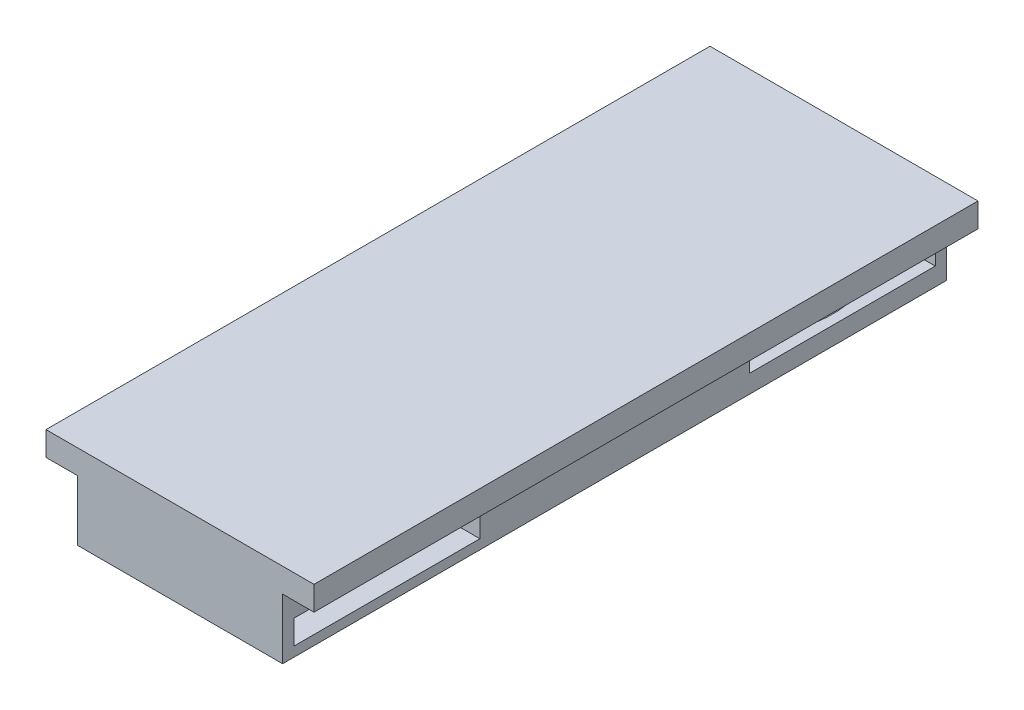
from build123d import *

# Parameters (mm, degrees)
BOSS_EXTRUDE1_DEPTH = 55
SKETCH3_R           = 7.7
CUT_EXTRUDE1_DEPTH  = 2.8
SKETCH4_R           = 7.7
SKETCH4_R_2         = 5.5
BOSS_EXTRUDE2_DEPTH = 0.8
SKETCH5_W           = 15.4
SKETCH5_H           = 2
CUT_EXTRUDE2_DEPTH  = 8.5


with BuildPart() as part:
    # Sketch2 → Boss-Extrude1 (new body)
    with BuildSketch(Plane.XY):
        Polygon((2.6, -1.780794077), (19.6, -1.780794077), (19.6, 3.219205923), (22.2, 3.219205923), (22.2, 5.219205923), (0, 5.219205923), (0, 3.219205923), (2.6, 3.219205923), align=None)
    extrude(amount=-BOSS_EXTRUDE1_DEPTH)

    # Sketch3 → Cut-Extrude1 (cut)
    with BuildSketch(Plane.XZ.offset(1.780794077)):
        with Locations((11.1, -8.64)):
            Circle(SKETCH3_R)
        with Locations((11.1, -46.36)):
            Circle(SKETCH3_R)
    extrude(amount=-CUT_EXTRUDE1_DEPTH, mode=Mode.SUBTRACT)

    # Sketch4 → Boss-Extrude2 (add)
    with BuildSketch(Plane.XZ.offset(1.780794077)):
        with Locations((11.1, -8.64)):
            Circle(SKETCH4_R)
        with Locations((11.1, -8.64)):
            Circle(SKETCH4_R_2, mode=Mode.SUBTRACT)
        with Locations((11.1, -46.36)):
            Circle(SKETCH4_R)
        with Locations((11.1, -46.36)):
            Circle(SKETCH4_R_2, mode=Mode.SUBTRACT)
    extrude(amount=-BOSS_EXTRUDE2_DEPTH)

    # Sketch5 → Cut-Extrude2 (cut)
    with BuildSketch(Plane(origin=(19.6, 0, 0), x_dir=(0, 0, -1), z_dir=(1, 0, 0))):
        with Locations((8.64, 0.019205923)):
            Rectangle(SKETCH5_W, SKETCH5_H)
        with Locations((46.36, 0.719205923)):
            Rectangle(SKETCH5_W, SKETCH5_H)
    extrude(amount=-CUT_EXTRUDE2_DEPTH, mode=Mode.SUBTRACT)


solid = part.part
